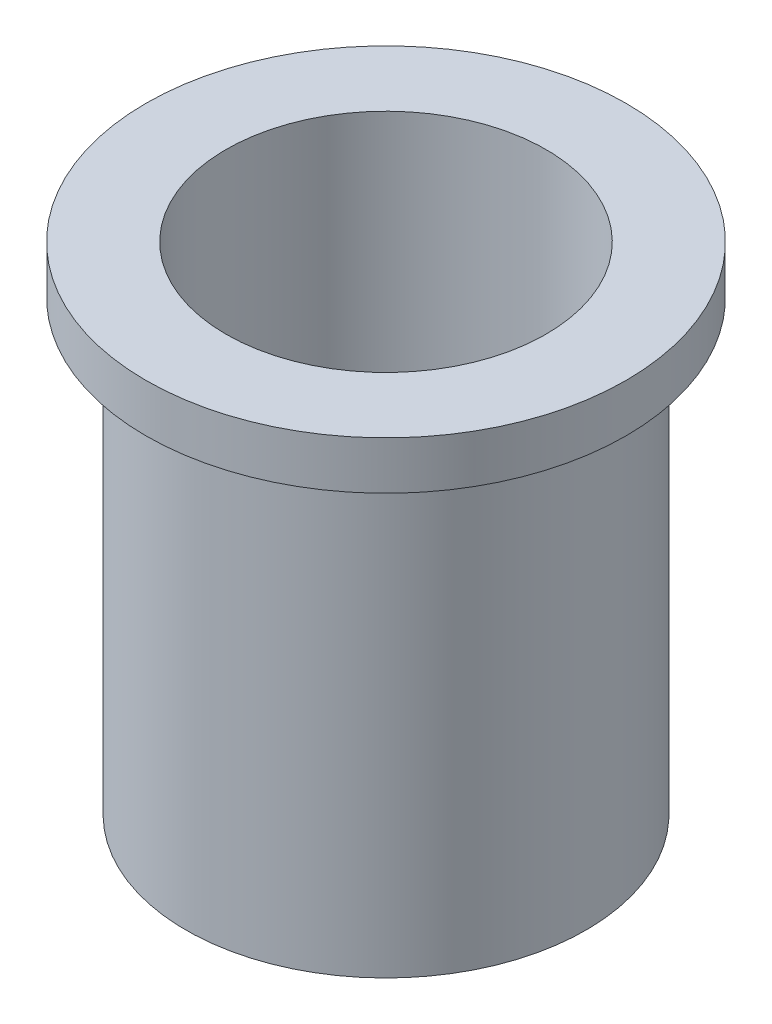
from build123d import *

# Parameters (mm, degrees)
SKETCH1_R           = 15
BOSS_EXTRUDE1_DEPTH = 1.5
SKETCH2_R           = 12.5
BOSS_EXTRUDE2_DEPTH = 28
SKETCH3_R           = 10
CUT_EXTRUDE1_DEPTH  = 32


with BuildPart() as part:
    # Sketch1 → Boss-Extrude1 (new body, symmetric)
    with BuildSketch(Plane(origin=(0, 0, 0), x_dir=(1, 0, 0), z_dir=(0, 1, 0))):
        Circle(SKETCH1_R)
    extrude(amount=BOSS_EXTRUDE1_DEPTH, both=True)

    # Sketch2 → Boss-Extrude2 (add)
    with BuildSketch(Plane.XZ.offset(1.5)):
        Circle(SKETCH2_R)
    extrude(amount=BOSS_EXTRUDE2_DEPTH)

    # Sketch3 → Cut-Extrude1 (cut, through all)
    with BuildSketch(Plane(origin=(0, 1.5, 0), x_dir=(1, 0, 0), z_dir=(0, 1, 0))):
        Circle(SKETCH3_R)
    extrude(amount=-CUT_EXTRUDE1_DEPTH, mode=Mode.SUBTRACT)


solid = part.part
